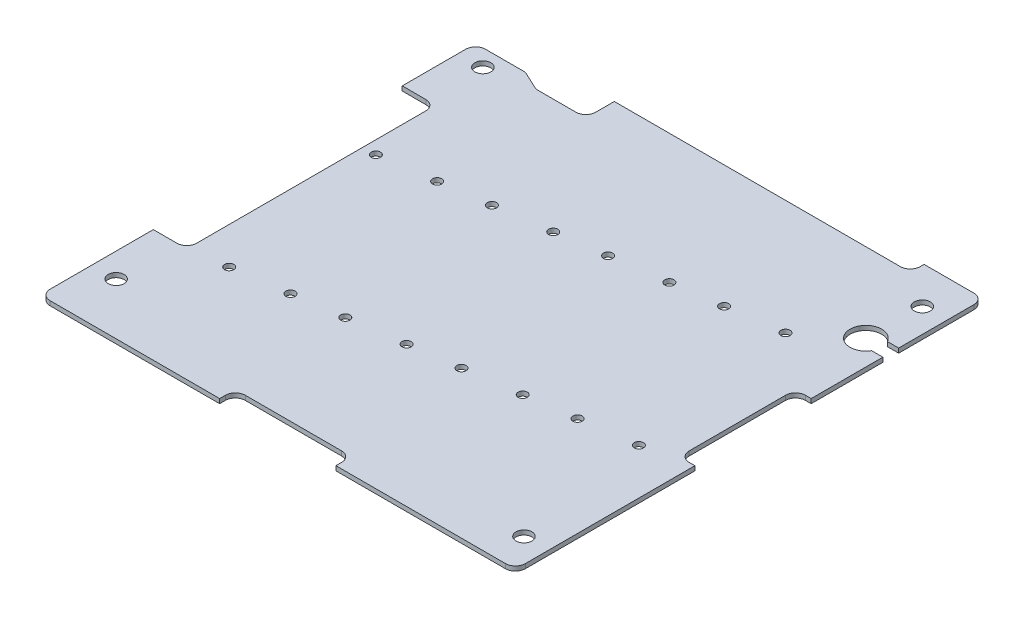
from build123d import *

# Parameters (mm, degrees)
SKETCH6_R          = 1.6
EXTRUDE1_DEPTH     = 0.9
FILLET1_R          = 2
SKETCH9_R          = 0.925
CUT_EXTRUDE1_DEPTH = 1.9
CUT_EXTRUDE2_DEPTH = 1.9


with BuildPart() as part:
    # Sketch6 → Extrude1 (new body)
    with BuildSketch(Plane(origin=(0, 0, 0), x_dir=(1, 0, 0), z_dir=(0, 1, 0))):
        Polygon((-4.8675, 77.0686), (-4.8675, 62.335), (1.8535, 62.335), (1.8535, 12.335), (-4.8675, 12.335), (-4.8675, -10.395), (31.1875, -10.395), (31.1875, -7.244), (54.5375, -7.244), (54.5375, -10.395), (90.5925, -10.395), (90.5925, 25.66), (87.4415, 25.66), (87.4415, 49.01), (90.5925, 49.01), (90.5925, 83.6934), (78.5925, 83.6934), (78.5925, 80.9186), (19.1449, 80.9186), (19.1449, 75.196571572), (9.1325, 75.196571572), (5.1325, 77.0686), align=None)
        with Locations((0, 73.66)):
            Circle(SKETCH6_R, mode=Mode.SUBTRACT)
        with Locations((85.725, 76.2)):
            Circle(SKETCH6_R, mode=Mode.SUBTRACT)
        Circle(SKETCH6_R, mode=Mode.SUBTRACT)
        with Locations((85.725, -3.81)):
            Circle(SKETCH6_R, mode=Mode.SUBTRACT)
    extrude(amount=EXTRUDE1_DEPTH)

    # Fillet1
    fillet1_edges = [part.edges().sort_by_distance(p)[0] for p in [
        (5.1325, 0.45, -77.0686),
        (9.1325, 0.45, -75.196571572),
        (19.1449, 0.45, -75.196571572),
        (78.5925, 0.45, -80.9186),
        (90.5925, 0.45, -83.6934),
        (87.4415, 0.45, -49.01),
        (87.4415, 0.45, -25.66),
        (90.5925, 0.45, 10.395),
        (54.5375, 0.45, 7.244),
        (31.1875, 0.45, 7.244),
        (-4.8675, 0.45, 10.395),
        (1.8535, 0.45, -12.335),
        (1.8535, 0.45, -62.335),
        (-4.8675, 0.45, -77.0686),
    ]]
    fillet(fillet1_edges, radius=FILLET1_R)

    # Sketch9 → Cut-Extrude1 (cut, through all)
    with BuildSketch(Plane.XZ):
        with Locations((4.454560153, -47.705692794)):
            Circle(SKETCH9_R)
        with Locations((15.248482102, -49.222679594)):
            Circle(SKETCH9_R)
        with Locations((9.269949446, -13.442417616)):
            Circle(SKETCH9_R)
        with Locations((20.063871395, -14.959404416)):
            Circle(SKETCH9_R)
        with Locations((29.718985107, -16.316341854)):
            Circle(SKETCH9_R)
        with Locations((24.903595814, -50.579617033)):
            Circle(SKETCH9_R)
        with Locations((35.697517763, -52.096603833)):
            Circle(SKETCH9_R)
        with Locations((40.512907056, -17.833328655)):
            Circle(SKETCH9_R)
        with Locations((50.168020768, -19.190266093)):
            Circle(SKETCH9_R)
        with Locations((45.352631475, -53.453541271)):
            Circle(SKETCH9_R)
        with Locations((56.146553424, -54.970528072)):
            Circle(SKETCH9_R)
        with Locations((60.961942717, -20.707252893)):
            Circle(SKETCH9_R)
        with Locations((65.801667136, -56.32746551)):
            Circle(SKETCH9_R)
        with Locations((70.617056429, -22.064190332)):
            Circle(SKETCH9_R)
        with Locations((81.410978378, -23.581177132)):
            Circle(SKETCH9_R)
        with Locations((76.595589085, -57.844452311)):
            Circle(SKETCH9_R)
    extrude(amount=-CUT_EXTRUDE1_DEPTH, mode=Mode.SUBTRACT)

    # Sketch11 → Cut-Extrude2 (cut, through all)
    with BuildSketch(Plane(origin=(0, 0.9, 0), x_dir=(1, 0, 0), z_dir=(0, 1, 0))):
        with BuildLine():
            Line((88.342130657, 63.4125), (90.5925, 63.4125))
            Line((90.5925, 63.4125), (90.5925, 66.5875))
            Line((90.5925, 66.5875), (88.342130657, 66.5875))
            ThreePointArc((88.342130657, 66.5875), (82.4175, 65), (88.342130657, 63.4125))
        make_face()
    extrude(amount=-CUT_EXTRUDE2_DEPTH, mode=Mode.SUBTRACT)


solid = part.part
